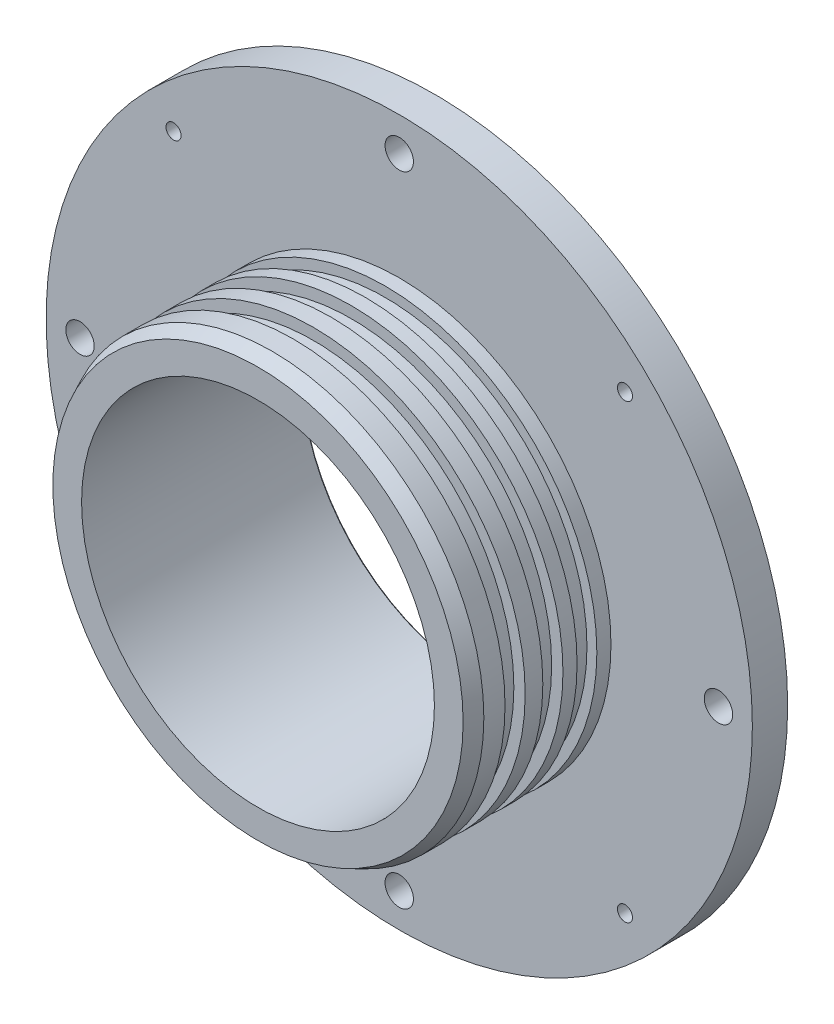
from build123d import *

# Parameters (mm, degrees)
CHAMFER2_SIZE          = 1.27
SKETCH7_R              = 31.7246
CUT_EXTRUDE1_DEPTH     = 15.55
F_6_32_TAPPED_HOLE1_D  = 2.7051
CIRPATTERN2_COUNT      = 4
F_10_CLEARANCE_HOLE1_D = 5.1054
CIRPATTERN3_COUNT      = 4
CHAMFER1_SIZE          = 2.54
CHAMFER1_SIZE2         = 1.184421452


with BuildPart() as part:
    # Sketch1 → Revolve1 (revolve)
    with BuildSketch(Plane(origin=(0, 0, 0), x_dir=(1, 0, 0), z_dir=(0, 1, 0))):
        Polygon((63.5, 0), (45.9994, 0), (45.9994, 0.254), (43.2181, 0.254), (43.2181, 5.0292), (45.9994, 5.0292), (45.9994, 8.2), (30.7594, 8.2), (30.7594, 0), (0, 0), (0, -6.35), (31.7246, -6.35), (31.7246, -31.75), (38.0746, -31.75), (38.0746, -25.4), (36.0426, -25.4), (36.0426, -21.7805), (38.0746, -21.7805), (38.0746, -18.6055), (36.0426, -18.6055), (36.0426, -14.986), (38.0746, -14.986), (38.0746, -12.446), (36.2966, -12.446), (36.2966, -8.89), (38.0746, -8.89), (38.0746, -6.35), (63.5, -6.35), align=None)
    revolve(axis=Axis((0, 0, 6.35), (0, 0, -1)))

    # Chamfer2
    chamfer2_edges = [part.edges().sort_by_distance(p)[0] for p in [
        (-45.9994, 0, -8.2),
        (-30.7594, 0, -8.2),
    ]]
    chamfer(chamfer2_edges, length=CHAMFER2_SIZE)

    # Sketch7 → Cut-Extrude1 (cut, through all)
    with BuildSketch(Plane.XY.offset(6.35)):
        Circle(SKETCH7_R)
    extrude(amount=-CUT_EXTRUDE1_DEPTH, mode=Mode.SUBTRACT)

    # #6-32 Tapped Hole1 (through all)
    with Locations(Plane(origin=(0, 0, 0), x_dir=(-1, 0, 0), z_dir=(0, 0, -1))):
        with Locations((40.590757667, 40.590757667)):
            f_6_32_tapped_hole1 = Hole(F_6_32_TAPPED_HOLE1_D / 2)

    # CirPattern2: #6-32 Tapped Hole1 ×4 about axis
    cirpattern2_axis = Axis((0, 0, 0), (0, 0, 1))
    for i in range(1, CIRPATTERN2_COUNT):
        add(f_6_32_tapped_hole1.rotate(cirpattern2_axis, i * 360 / CIRPATTERN2_COUNT), mode=Mode.SUBTRACT)

    # #10 Clearance Hole1 (through all)
    with Locations(Plane(origin=(0, 0, 0), x_dir=(-1, 0, 0), z_dir=(0, 0, -1))):
        with Locations((0, 57.404)):
            f_10_clearance_hole1 = Hole(F_10_CLEARANCE_HOLE1_D / 2)

    # CirPattern3: #10 Clearance Hole1 ×4 about axis
    cirpattern3_axis = Axis((0, 0, 0), (0, 0, 1))
    for i in range(1, CIRPATTERN3_COUNT):
        add(f_10_clearance_hole1.rotate(cirpattern3_axis, i * 360 / CIRPATTERN3_COUNT), mode=Mode.SUBTRACT)

    # Chamfer1
    chamfer1_edges = [part.edges().sort_by_distance(p)[0] for p in [
        (-38.0746, 0, 31.75),
    ]]
    chamfer1_side = [part.faces().sort_by_distance(p)[0] for p in [
        (-38.0746, 0, 28.575),
    ]]
    chamfer(chamfer1_edges, length=CHAMFER1_SIZE, length2=CHAMFER1_SIZE2, reference=chamfer1_side[0])


solid = part.part
